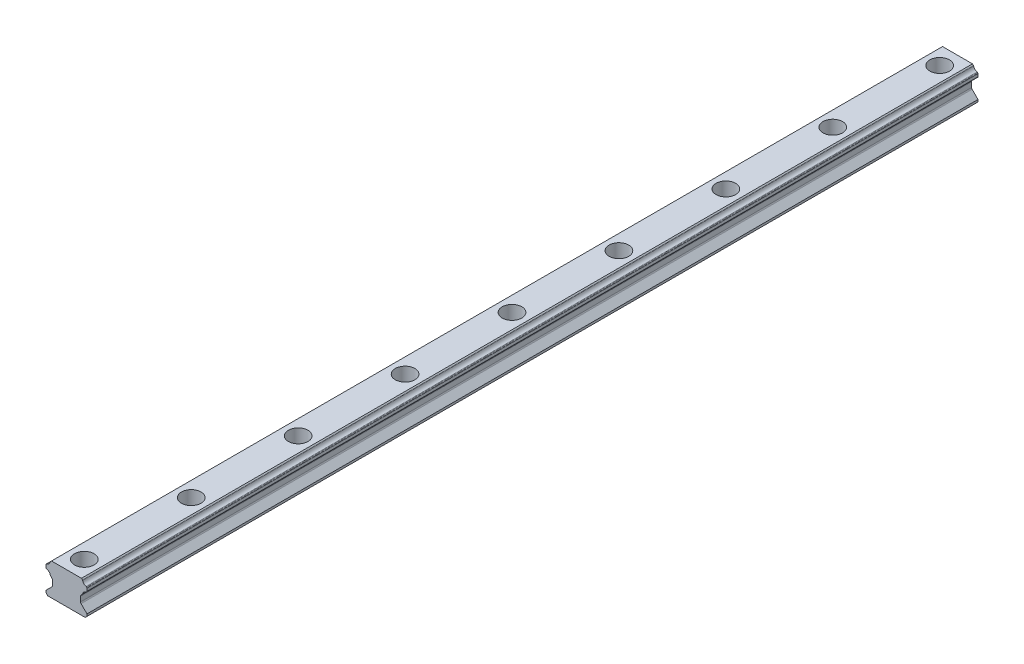
from build123d import *

# Parameters (mm, degrees)
BOSS_EXTRUDE1_DEPTH                                 = 500
CBORE_FOR_M6_HEX_SOCKET_HEAD_CAP_SCREW1_D           = 7
CBORE_FOR_M6_HEX_SOCKET_HEAD_CAP_SCREW1_CBORE_D     = 11
CBORE_FOR_M6_HEX_SOCKET_HEAD_CAP_SCREW1_CBORE_DEPTH = 9
LPATTERN1_COUNT                                     = 9
LPATTERN1_PITCH                                     = 60


with BuildPart() as part:
    # Sketch1 → Boss-Extrude1 (new body)
    with BuildSketch(Plane.XY):
        with BuildLine():
            Line((-8.192893219, -12.452822372), (-11.5, -15.759929153))
            Line((-11.5, -15.759929153), (-11.5, -17))
            Line((-11.5, -17), (-10.5, -18))
            Line((-10.5, -18), (10.5, -18))
            Line((10.5, -18), (11.5, -17))
            Line((11.5, -17), (11.5, -15.759929153))
            Line((11.5, -15.759929153), (8.192893219, -12.452822372))
            ThreePointArc((8.192893219, -12.452822372), (7.976120468, -12.128399023), (7.9, -11.745715591))
            Line((7.9, -11.745715591), (7.9, -8.934076562))
            ThreePointArc((7.9, -8.934076562), (7.976120468, -8.55139313), (8.192893219, -8.226969781))
            Line((8.192893219, -8.226969781), (8.93515621, -7.48470679))
            ThreePointArc((8.93515621, -7.48470679), (9.020912002, -7.369915712), (9.070589884, -7.235516473))
            ThreePointArc((9.070589884, -7.235516473), (9.728797536, -6.024451536), (10.939862473, -5.366243884))
            ThreePointArc((10.939862473, -5.366243884), (11.074261712, -5.316566002), (11.18905279, -5.23081021))
            Line((11.18905279, -5.23081021), (11.353553391, -5.066309609))
            ThreePointArc((11.353553391, -5.066309609), (11.461939766, -4.904097935), (11.5, -4.712756219))
            Line((11.5, -4.712756219), (11.5, -3.298408781))
            ThreePointArc((11.5, -3.298408781), (11.461939766, -3.107067065), (11.353553391, -2.944855391))
            Line((11.353553391, -2.944855391), (11.175123458, -2.766425458))
            ThreePointArc((11.175123458, -2.766425458), (11.061399997, -2.681251593), (10.928310161, -2.631505152))
            ThreePointArc((10.928310161, -2.631505152), (9.728797536, -1.975792464), (9.073084848, -0.776279839))
            ThreePointArc((9.073084848, -0.776279839), (9.023338407, -0.643190003), (8.938164542, -0.529466542))
            Line((8.938164542, -0.529466542), (8.408698, 0))
            Line((8.408698, 0), (-8.408698, 0))
            Line((-8.408698, 0), (-8.938164542, -0.529466542))
            ThreePointArc((-8.938164542, -0.529466542), (-9.023338407, -0.643190003), (-9.073084848, -0.776279839))
            ThreePointArc((-9.073084848, -0.776279839), (-9.728797536, -1.975792464), (-10.928310161, -2.631505152))
            ThreePointArc((-10.928310161, -2.631505152), (-11.061399997, -2.681251593), (-11.175123458, -2.766425458))
            Line((-11.175123458, -2.766425458), (-11.353553391, -2.944855391))
            ThreePointArc((-11.353553391, -2.944855391), (-11.461939766, -3.107067065), (-11.5, -3.298408781))
            Line((-11.5, -3.298408781), (-11.5, -4.712756219))
            ThreePointArc((-11.5, -4.712756219), (-11.461939766, -4.904097935), (-11.353553391, -5.066309609))
            Line((-11.353553391, -5.066309609), (-11.18905279, -5.23081021))
            ThreePointArc((-11.18905279, -5.23081021), (-11.074261712, -5.316566002), (-10.939862473, -5.366243884))
            ThreePointArc((-10.939862473, -5.366243884), (-9.728797536, -6.024451536), (-9.070589884, -7.235516473))
            ThreePointArc((-9.070589884, -7.235516473), (-9.020912002, -7.369915712), (-8.93515621, -7.48470679))
            Line((-8.93515621, -7.48470679), (-8.192893219, -8.226969781))
            ThreePointArc((-8.192893219, -8.226969781), (-7.976120468, -8.55139313), (-7.9, -8.934076562))
            Line((-7.9, -8.934076562), (-7.9, -11.745715591))
            ThreePointArc((-7.9, -11.745715591), (-7.976120468, -12.128399023), (-8.192893219, -12.452822372))
        make_face()
    extrude(amount=BOSS_EXTRUDE1_DEPTH)

    # CBORE for M6 Hex Socket Head Cap Screw1 (through all)
    with Locations(Plane(origin=(0, 0, 10), x_dir=(0, 0, 1), z_dir=(0, 1, 0))):
        with Locations((0, 0)):
            cbore_for_m6_hex_socket_head_cap_screw1 = CounterBoreHole(CBORE_FOR_M6_HEX_SOCKET_HEAD_CAP_SCREW1_D / 2, CBORE_FOR_M6_HEX_SOCKET_HEAD_CAP_SCREW1_CBORE_D / 2, CBORE_FOR_M6_HEX_SOCKET_HEAD_CAP_SCREW1_CBORE_DEPTH)

    # LPattern1: CBORE for M6 Hex Socket Head Cap Screw1 ×9
    with Locations(*[(0, 0, i * LPATTERN1_PITCH) for i in range(1, LPATTERN1_COUNT)]):
        add(cbore_for_m6_hex_socket_head_cap_screw1, mode=Mode.SUBTRACT)


solid = part.part
